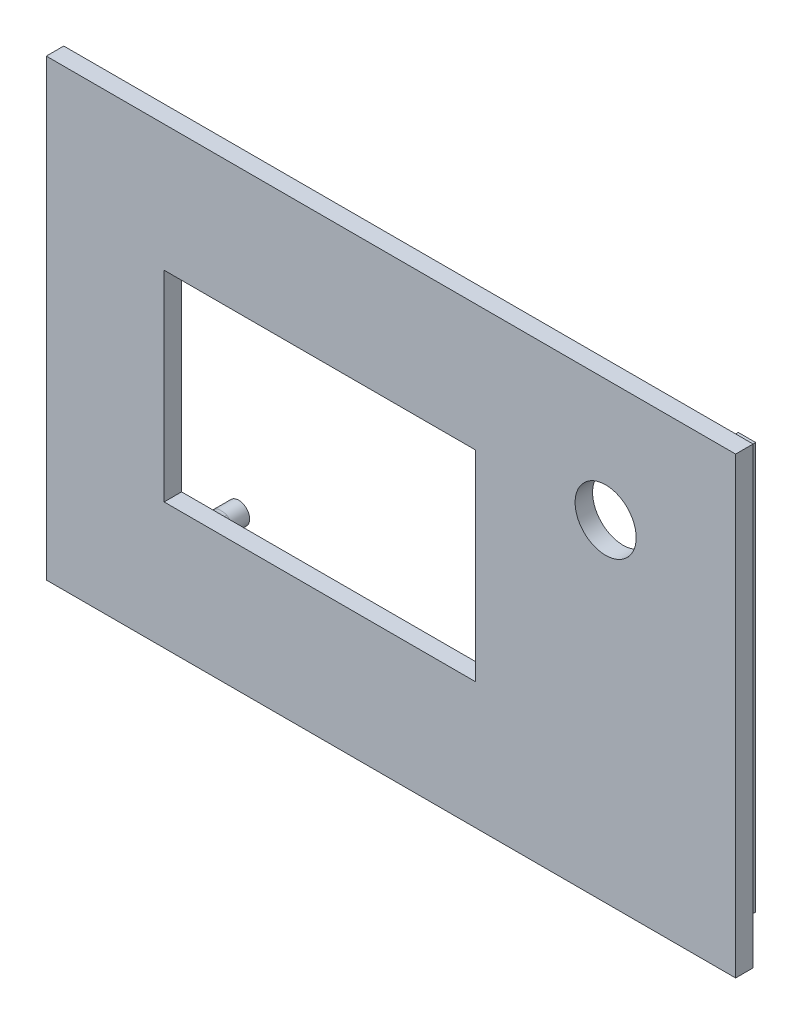
from build123d import *

# Parameters (mm, degrees)
SKIZZE10_W                       = 79
SKIZZE10_H                       = 52
AUFSATZ_LINEAR_AUSTRAGEN8_DEPTH  = 2
SKIZZE11_W                       = 35.7
SKIZZE11_H                       = 23
SCHNITT_LINEAR_AUSTRAGEN3_DEPTH  = 2
SKIZZE13_R                       = 3.5
SCHNITT_LINEAR_AUSTRAGEN4_DEPTH  = 2
SKIZZE14_R                       = 1.25
AUFSATZ_LINEAR_AUSTRAGEN9_DEPTH  = 4
AUFSATZ_LINEAR_AUSTRAGEN10_DEPTH = 3
VERRUNDUNG1_R                    = 2


with BuildPart() as part:
    # Skizze10 → Aufsatz-Linear austragen8 (new body)
    with BuildSketch(Plane.XY):
        with Locations((-19.990421456, -28.402298851)):
            Rectangle(SKIZZE10_W, SKIZZE10_H)
    extrude(amount=AUFSATZ_LINEAR_AUSTRAGEN8_DEPTH)

    # Skizze11 → Schnitt-Linear austragen3 (cut)
    with BuildSketch(Plane.XY.offset(2)):
        with Locations((-28.136972684, -28.402298851)):
            Rectangle(SKIZZE11_W, SKIZZE11_H)
    extrude(amount=-SCHNITT_LINEAR_AUSTRAGEN3_DEPTH, mode=Mode.SUBTRACT)

    # Skizze13 → Schnitt-Linear austragen4 (cut)
    with BuildSketch(Plane.XY.offset(2)):
        with Locations((4.61130293, -16.402298851)):
            Circle(SKIZZE13_R)
    extrude(amount=-SCHNITT_LINEAR_AUSTRAGEN4_DEPTH, mode=Mode.SUBTRACT)

    # Skizze14 → Aufsatz-Linear austragen9 (add)
    with BuildSketch(Plane(origin=(0, 0, 0), x_dir=(-1, 0, 0), z_dir=(0, 0, -1))):
        with Locations((43.436972684, -14.102298851)):
            Circle(SKIZZE14_R)
        with Locations((43.436972684, -42.702298851)):
            Circle(SKIZZE14_R)
        with Locations((12.836972684, -14.102298851)):
            Circle(SKIZZE14_R)
        with Locations((12.836972684, -42.702298851)):
            Circle(SKIZZE14_R)
    extrude(amount=AUFSATZ_LINEAR_AUSTRAGEN9_DEPTH)

    # Skizze15 → Aufsatz-Linear austragen10 (add)
    with BuildSketch(Plane(origin=(0, 0, 0), x_dir=(-1, 0, 0), z_dir=(0, 0, -1))):
        Polygon((-16.809578544, -5.102298851), (-16.809578544, -51.702298851), (56.790421456, -51.702298851), (56.790421456, -49.702298851), (-14.809578544, -49.702298851), (-14.809578544, -5.102298851), align=None)
    extrude(amount=AUFSATZ_LINEAR_AUSTRAGEN10_DEPTH)

    # Verrundung1
    verrundung1_edges = [part.edges().sort_by_distance(p)[0] for p in [
        (-42.186972684, -14.102298851, 0),
        (-42.186972684, -42.702298851, 0),
        (-11.586972684, -14.102298851, 0),
        (-11.586972684, -42.702298851, 0),
    ]]
    fillet(verrundung1_edges, radius=VERRUNDUNG1_R)


solid = part.part
